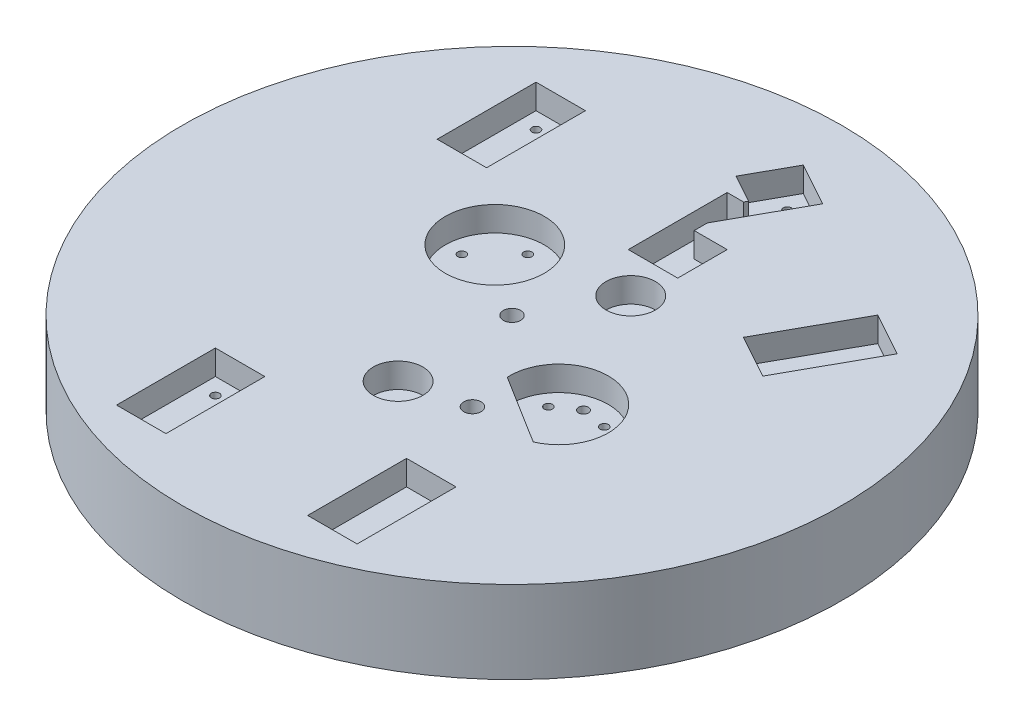
from build123d import *

# Parameters (mm, degrees)
SKETCH1_R                  = 200
BOSS_EXTRUDE1_DEPTH        = 50
SKETCH2_R                  = 15
SKETCH2_R_2                = 30
CUT_EXTRUDE1_DEPTH         = 15
M12X1_5_TAPPED_HOLE1_D     = 10.5
M12X1_5_TAPPED_HOLE1_DEPTH = 25.34548175
M12X1_5_TAPPED_HOLE1_TIP   = 3.15451825
CIRPATTERN5_COUNT          = 3
CIRPATTERN5_ANGLE          = 180
CIRPATTERN6_COUNT          = 4
M12X1_5_TAPPED_HOLE2_D     = 10.5
M12X1_5_TAPPED_HOLE2_DEPTH = 25.34548175
M12X1_5_TAPPED_HOLE2_TIP   = 3.15451825
SKETCH3_W                  = 30
SKETCH3_H                  = 60
CUT_EXTRUDE2_DEPTH         = 15
M6_TAPPED_HOLE3_D          = 5
M6_TAPPED_HOLE3_DEPTH      = 13.497848452
M6_TAPPED_HOLE3_TIP        = 1.502151548
SKETCH32_R                 = 3
CUT_EXTRUDE3_DEPTH         = 15
M12X1_5_TAPPED_HOLE3_D     = 10.5
M12X1_5_TAPPED_HOLE3_DEPTH = 25.34548175
M12X1_5_TAPPED_HOLE3_TIP   = 3.15451825


with BuildPart() as part:
    # Sketch1 → Boss-Extrude1 (new body)
    with BuildSketch(Plane(origin=(0, 0, 0), x_dir=(1, 0, 0), z_dir=(0, 1, 0))):
        Circle(SKETCH1_R)
    extrude(amount=BOSS_EXTRUDE1_DEPTH)

    # Sketch2 → Cut-Extrude1 (cut)
    with BuildSketch(Plane(origin=(0, 50, 0), x_dir=(1, 0, 0), z_dir=(0, 1, 0))):
        with Locations((0, -69.113872591)):
            Circle(SKETCH2_R)
        with Locations((25.69461295, 46.354666069)):
            Circle(SKETCH2_R)
        with Locations((-42.327685627, 31.896492385)):
            Circle(SKETCH2_R_2)
        with BuildLine():
            Line((31.001143439, -33.886276935), (72.945217779, -60.052947106))
            ThreePointArc((72.945217779, -60.052947106), (76.850049502, -7.09303501), (31.001143439, -33.886276935))
        make_face()
    extrude(amount=-CUT_EXTRUDE1_DEPTH, mode=Mode.SUBTRACT)

    # M12x1.5 Tapped Hole1
    with Locations(Plane(origin=(0, 35, 0), x_dir=(1, 0, 0), z_dir=(0, 1, 0))):
        with Locations((25.69461295, 46.354666069), (0, -69.113872591)):
            Hole(M12X1_5_TAPPED_HOLE1_D / 2, depth=M12X1_5_TAPPED_HOLE1_DEPTH)
            with Locations((0, 0, -(M12X1_5_TAPPED_HOLE1_DEPTH + M12X1_5_TAPPED_HOLE1_TIP / 2))):  # 118° drill point
                Cone(0, M12X1_5_TAPPED_HOLE1_D / 2, M12X1_5_TAPPED_HOLE1_TIP, mode=Mode.SUBTRACT)

    # Sketch18 → M6 Tapped Hole1 (revolve, cut)
    with BuildSketch(Plane(origin=(44.002440842, 35, 21.960267616), x_dir=(0, 0, 1), z_dir=(1, 0, 0))):
        Polygon((0, 0), (0, 15), (2.5, 13.497848452), (2.5, 0), align=None)
    m6_tapped_hole1 = revolve(axis=Axis((44.002440842, 41.35, 21.960267616), (0, -1, 0)), mode=Mode.SUBTRACT)

    # CirPattern5: M6 Tapped Hole1 ×3 about axis
    cirpattern5_axis = Axis((60.971197017, 35, 32.546169272), (0, -1, 0))
    for i in range(1, CIRPATTERN5_COUNT):
        add(m6_tapped_hole1.rotate(cirpattern5_axis, i * CIRPATTERN5_ANGLE / (CIRPATTERN5_COUNT - 1)), mode=Mode.SUBTRACT)

    # Sketch21 → M6 Tapped Hole2 (revolve, cut)
    with BuildSketch(Plane(origin=(-42.327685627, 35, -51.896492385), x_dir=(0, 0, 1), z_dir=(1, 0, 0))):
        Polygon((0, 0), (0, 15), (2.5, 13.497848452), (2.5, 0), align=None)
    m6_tapped_hole2 = revolve(axis=Axis((-42.327685627, 41.35, -51.896492385), (0, -1, 0)), mode=Mode.SUBTRACT)

    # CirPattern6: M6 Tapped Hole2 ×4 about axis
    cirpattern6_axis = Axis((-42.327685627, 35, -31.896492385), (0, 1, 0))
    for i in range(1, CIRPATTERN6_COUNT):
        add(m6_tapped_hole2.rotate(cirpattern6_axis, i * 360 / CIRPATTERN6_COUNT), mode=Mode.SUBTRACT)

    # M12x1.5 Tapped Hole2
    with Locations(Plane(origin=(0, 50, 0), x_dir=(1, 0, 0), z_dir=(0, 1, 0))):
        with Locations((-0.014790744, 0.024833856)):
            Hole(M12X1_5_TAPPED_HOLE2_D / 2, depth=M12X1_5_TAPPED_HOLE2_DEPTH)
            with Locations((0, 0, -(M12X1_5_TAPPED_HOLE2_DEPTH + M12X1_5_TAPPED_HOLE2_TIP / 2))):  # 118° drill point
                Cone(0, M12X1_5_TAPPED_HOLE2_D / 2, M12X1_5_TAPPED_HOLE2_TIP, mode=Mode.SUBTRACT)

    # Sketch3 → Cut-Extrude2 (cut)
    with BuildSketch(Plane(origin=(0, 50, 0), x_dir=(1, 0, 0), z_dir=(0, 1, 0))):
        with Locations((58.112318667, -137.113872591)):
            Rectangle(SKETCH3_W, SKETCH3_H)
        Polygon((137.053029906, 96.676659004), (110.814391162, 111.220861865), (81.72598544, 58.743584377), (107.964624184, 44.199381516), align=None)
        with Locations((-100.327685627, 99.896492385)):
            Rectangle(SKETCH3_W, SKETCH3_H)
        with Locations((-57.887681333, -137.113872591)):
            Rectangle(SKETCH3_W, SKETCH3_H)
        Polygon((35.596960096, 152.9142434), (9.358321352, 167.458446261), (-5.185881509, 141.219807517), (11.746380439, 131.834173793), (10.672314373, 129.896492385), (0.672314373, 129.896492385), (0.672314373, 69.896492385), (30.672314373, 69.896492385), (30.672314373, 99.896492385), (10.672314373, 99.896492385), (10.672314373, 107.948645684), align=None)
    extrude(amount=-CUT_EXTRUDE2_DEPTH, mode=Mode.SUBTRACT)

    # M6 Tapped Hole3
    with Locations(Plane(origin=(0, 35, 0), x_dir=(1, 0, 0), z_dir=(0, 1, 0))):
        with Locations((123.458749371, 92.77851371), (104.06647889, 57.793662051), (-105.327685627, 119.896492385), (-105.327685627, 79.896492385), (-62.887681333, -117.113872591), (-62.887681333, -157.113872591), (63.112318667, -117.113872591), (63.112318667, -157.113872591), (13.256466646, 153.864165726), (20.672314373, 79.896492385)):
            Hole(M6_TAPPED_HOLE3_D / 2, depth=M6_TAPPED_HOLE3_DEPTH)
            with Locations((0, 0, -(M6_TAPPED_HOLE3_DEPTH + M6_TAPPED_HOLE3_TIP / 2))):  # 118° drill point
                Cone(0, M6_TAPPED_HOLE3_D / 2, M6_TAPPED_HOLE3_TIP, mode=Mode.SUBTRACT)

    # Sketch32 → Cut-Extrude3 (cut)
    with BuildSketch(Plane(origin=(0, 35, 0), x_dir=(1, 0, 0), z_dir=(0, 1, 0))):
        with Locations((56.457837304, -13.062083867)):
            Circle(SKETCH32_R)
    extrude(amount=-CUT_EXTRUDE3_DEPTH, mode=Mode.SUBTRACT)

    # M12x1.5 Tapped Hole3
    with Locations(Plane(origin=(0, 50, 0), x_dir=(1, 0, 0), z_dir=(0, 1, 0))):
        with Locations((35.989041426, -60.006192032)):
            Hole(M12X1_5_TAPPED_HOLE3_D / 2, depth=M12X1_5_TAPPED_HOLE3_DEPTH)
            with Locations((0, 0, -(M12X1_5_TAPPED_HOLE3_DEPTH + M12X1_5_TAPPED_HOLE3_TIP / 2))):  # 118° drill point
                Cone(0, M12X1_5_TAPPED_HOLE3_D / 2, M12X1_5_TAPPED_HOLE3_TIP, mode=Mode.SUBTRACT)


solid = part.part
